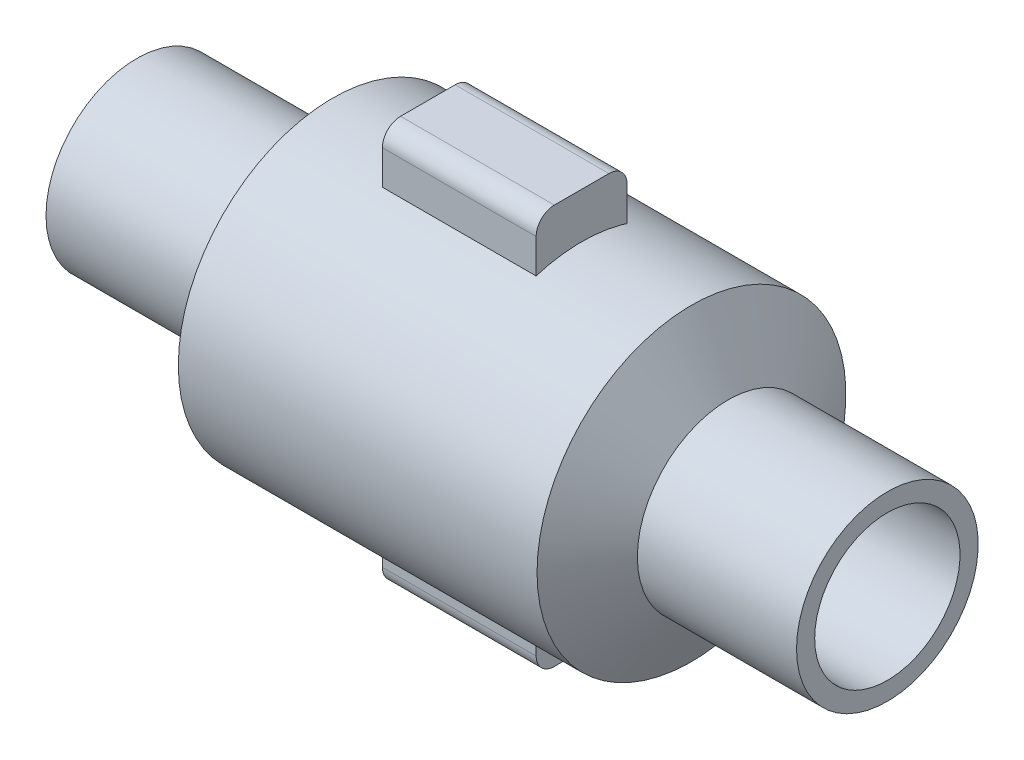
from build123d import *

# Parameters (mm, degrees)
SKETCH3_W                = 338.550765942
SKETCH3_H                = 200.186539862
BOSS_EXTRUDE1_DEPTH      = 100
BOSS_EXTRUDE1_DEPTH_BACK = 40
FILLET1_R                = 40
SKETCH5_W                = 338.550765942
SKETCH5_H                = 200.186539862
BOSS_EXTRUDE2_DEPTH      = 99.999999898
BOSS_EXTRUDE2_DEPTH_BACK = 40
FILLET2_R                = 40


with BuildPart() as part:
    # Sketch1 → Revolve1 (revolve)
    with BuildSketch(Plane.XY):
        Polygon((0, 159.99999878), (0, 199.99999878), (350.52, 199.99999878), (431.34903734, 339.99999818), (1221.28903734, 339.99999818), (1302.11807468, 199.99999878), (1652.63807468, 199.99999878), (1652.63807468, 159.99999878), (1626.618760092, 159.99999878), (1302.11807468, 159.99999878), (1218.74903734, 299.99999818), (428.80903734, 299.99999818), (350.52, 159.99999878), (39.855878474, 159.99999878), align=None)
    revolve(axis=Axis((0, 0, 0), (1, 0, 0)))


with BuildPart() as body_2:
    # Sketch3 → Boss-Extrude1 (new body, two sides)
    with BuildSketch(Plane(origin=(0, 339.999999958, 0), x_dir=(1, 0, 0), z_dir=(0, 1, 0))) as boss_extrude1_sk:
        with Locations((810.127478969, 0)):
            Rectangle(SKETCH3_W, SKETCH3_H)
    extrude(amount=BOSS_EXTRUDE1_DEPTH)
    extrude(boss_extrude1_sk.sketch, amount=-BOSS_EXTRUDE1_DEPTH_BACK)

    # Fillet1
    fillet1_edges = [body_2.edges().sort_by_distance(p)[0] for p in [
        (810.127478969, 439.999999958, -100.093269931),
        (810.127478969, 439.999999958, 100.093269931),
    ]]
    fillet(fillet1_edges, radius=FILLET1_R)


with BuildPart() as body_3:
    # Sketch5 → Boss-Extrude2 (new body, two sides)
    with BuildSketch(Plane(origin=(0, -339.999999958, 0), x_dir=(-1, 0, 0), z_dir=(0, -1, 0))) as boss_extrude2_sk:
        with Locations((-810.127478969, 0)):
            Rectangle(SKETCH5_W, SKETCH5_H)
    extrude(amount=BOSS_EXTRUDE2_DEPTH)
    extrude(boss_extrude2_sk.sketch, amount=-BOSS_EXTRUDE2_DEPTH_BACK)

    # Fillet2
    fillet2_edges = [body_3.edges().sort_by_distance(p)[0] for p in [
        (810.127478969, -439.999999856, 100.093269931),
        (810.127478969, -439.999999856, -100.093269931),
    ]]
    fillet(fillet2_edges, radius=FILLET2_R)


solid = Compound([part.part, body_2.part, body_3.part])
